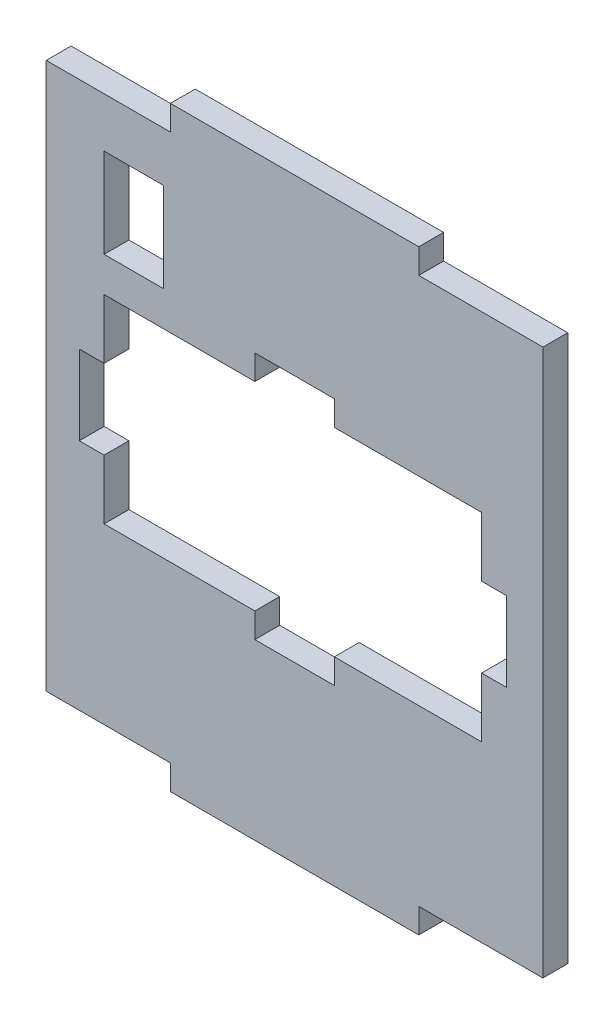
from build123d import *

# Parameters (mm, degrees)
SKETCH1_W           = 12
SKETCH1_H           = 18
BOSS_EXTRUDE1_DEPTH = 5


with BuildPart() as part:
    # Sketch1 → Boss-Extrude1 (new body)
    with BuildSketch(Plane.XY):
        Polygon((-25, 60), (25, 60), (25, 55), (50, 55), (50, -55), (25, -55), (25, -60), (-25, -60), (-25, -55), (-50, -55), (-50, 55), (-25, 55), align=None)
        Polygon((37.651162791, 8), (42.651162791, 8), (42.651162791, -8), (37.651162791, -8), (37.651162791, -20), (8, -20), (8, -25), (-8, -25), (-8, -20), (-38.348837209, -20), (-38.348837209, -8), (-43.348837209, -8), (-43.348837209, 8), (-38.348837209, 8), (-38.348837209, 20), (-8, 20), (-8, 25), (8, 25), (8, 20), (37.651162791, 20), align=None, mode=Mode.SUBTRACT)
        with Locations((-32.348837209, 36)):
            Rectangle(SKETCH1_W, SKETCH1_H, mode=Mode.SUBTRACT)
    extrude(amount=BOSS_EXTRUDE1_DEPTH)


solid = part.part
